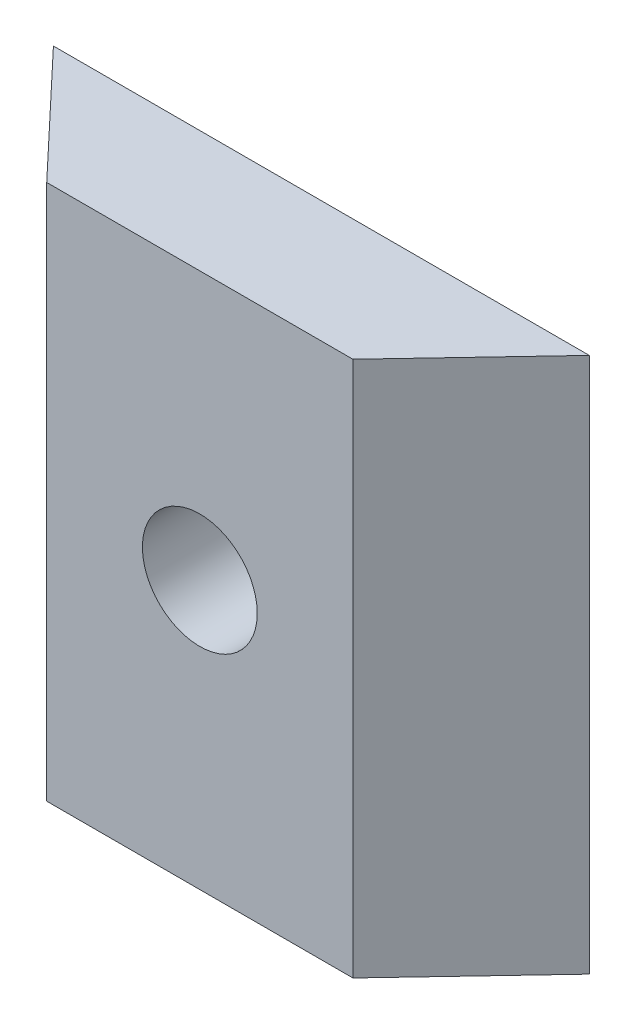
from build123d import *

# Parameters (mm, degrees)
ESBO_O1_W                = 14
ESBO_O1_H                = 14
RESSALTO_EXTRUS_O1_DEPTH = 3.175
CORTE_EXTRUS_O1_DEPTH    = 15
ESBO_O10_R               = 1.5
CORTE_EXTRUS_O2_DEPTH    = 4.175


with BuildPart() as part:
    # Esboço1 → Ressalto-extrusão1 (new body)
    with BuildSketch(Plane.XY):
        Rectangle(ESBO_O1_W, ESBO_O1_H)
    extrude(amount=RESSALTO_EXTRUS_O1_DEPTH)

    # Esboço2 → Corte-extrusão1 (cut, through all)
    with BuildSketch(Plane.XZ.offset(7)):
        Polygon((-4, 3.175), (-7, 3.175), (-7, 0), align=None)
        Polygon((4, 3.175), (7, 3.175), (7, 0), align=None)
    extrude(amount=-CORTE_EXTRUS_O1_DEPTH, mode=Mode.SUBTRACT)

    # Esboço10 → Corte-extrusão2 (cut, through all)
    with BuildSketch(Plane.XY.offset(3.175)):
        Circle(ESBO_O10_R)
    extrude(amount=-CORTE_EXTRUS_O2_DEPTH, mode=Mode.SUBTRACT)


solid = part.part
